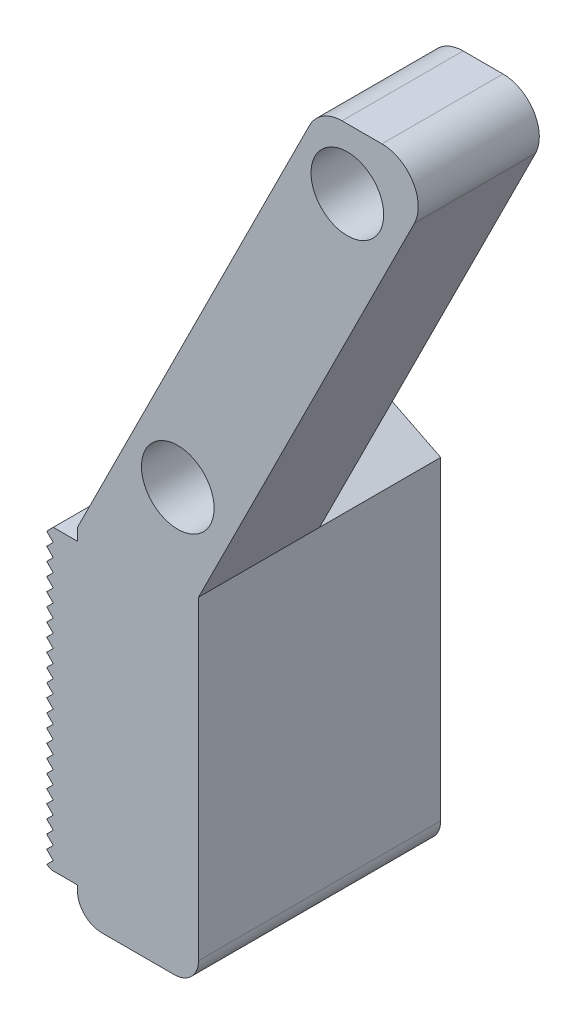
from build123d import *

# Parameters (mm, degrees)
SKETCH2_R           = 1.5
BOSS_EXTRUDE1_DEPTH = 10
SKETCH4_W           = 5
SKETCH4_H           = 22.360679775
CUT_EXTRUDE1_DEPTH  = 10
FILLET1_R           = 1.5
FILLET2_R           = 1
BOSS_EXTRUDE2_DEPTH = 10


with BuildPart() as part:
    # Sketch2 → Boss-Extrude1 (new body)
    with BuildSketch(Plane.XY):
        Polygon((0, 0), (-5, 0), (-15, -20), (-15, -34), (-10, -34), (-10, -20), align=None)
        with Locations((-3.855019194, -2.5)):
            Circle(SKETCH2_R, mode=Mode.SUBTRACT)
        with Locations((-10.857407264, -16.5)):
            Circle(SKETCH2_R, mode=Mode.SUBTRACT)
    extrude(amount=BOSS_EXTRUDE1_DEPTH)

    # Sketch4 → Cut-Extrude1 (cut)
    with BuildSketch(Plane(origin=(0, 0, 0), x_dir=(0, 0, -1), z_dir=(0.894427191, -0.447213595, 0))):
        with Locations((-2.5, -11.180339888)):
            Rectangle(SKETCH4_W, SKETCH4_H)
    extrude(amount=-CUT_EXTRUDE1_DEPTH, mode=Mode.SUBTRACT)

    # Fillet1
    fillet1_edges = [part.edges().sort_by_distance(p)[0] for p in [
        (-5, 0, 7.5),
        (0, 0, 7.5),
    ]]
    fillet(fillet1_edges, radius=FILLET1_R)

    # Fillet2
    fillet2_edges = [part.edges().sort_by_distance(p)[0] for p in [
        (-15, -34, 5),
        (-10, -34, 5),
    ]]
    fillet(fillet2_edges, radius=FILLET2_R)

    # Sketch5 → Boss-Extrude2 (add)
    with BuildSketch(Plane.XY.offset(10)):
        Polygon((-15, -20.5), (-16, -20.5), (-16.270880122, -20.770880122), (-16, -21.041760245), (-16.270880122, -21.312640367), (-16, -21.58352049), (-16.270880122, -21.854400612), (-16, -22.125280734), (-16.270880122, -22.396160857), (-16, -22.667040979), (-16.270880122, -22.937921102), (-16, -23.208801224), (-16.270880122, -23.479681346), (-16, -23.750561469), (-16.270880122, -24.021441591), (-16, -24.292321714), (-16.270880122, -24.563201836), (-16, -24.834081958), (-16.270880122, -25.104962081), (-16, -25.375842203), (-16.270880122, -25.646722326), (-16, -25.917602448), (-16.270880122, -26.188482571), (-16, -26.459362693), (-16.270880122, -26.730242815), (-16, -27.001122938), (-16.270880122, -27.27200306), (-16, -27.542883183), (-16.270880122, -27.813763305), (-16, -28.084643427), (-16.270880122, -28.35552355), (-16, -28.626403672), (-16.270880122, -28.897283795), (-16, -29.168163917), (-16.270880122, -29.439044039), (-16, -29.709924162), (-16.270880122, -29.980804284), (-16, -30.251684407), (-16.270880122, -30.522564529), (-16, -30.793444651), (-16.270880122, -31.064324774), (-16, -31.335204896), (-16.270880122, -31.606085019), (-16, -31.876965141), (-16.270880122, -32.147845263), (-16, -32.418725386), (-16.270880122, -32.689605508), (-16.070783647, -32.79), (-15, -32.79), align=None)
    extrude(amount=-BOSS_EXTRUDE2_DEPTH)


solid = part.part
